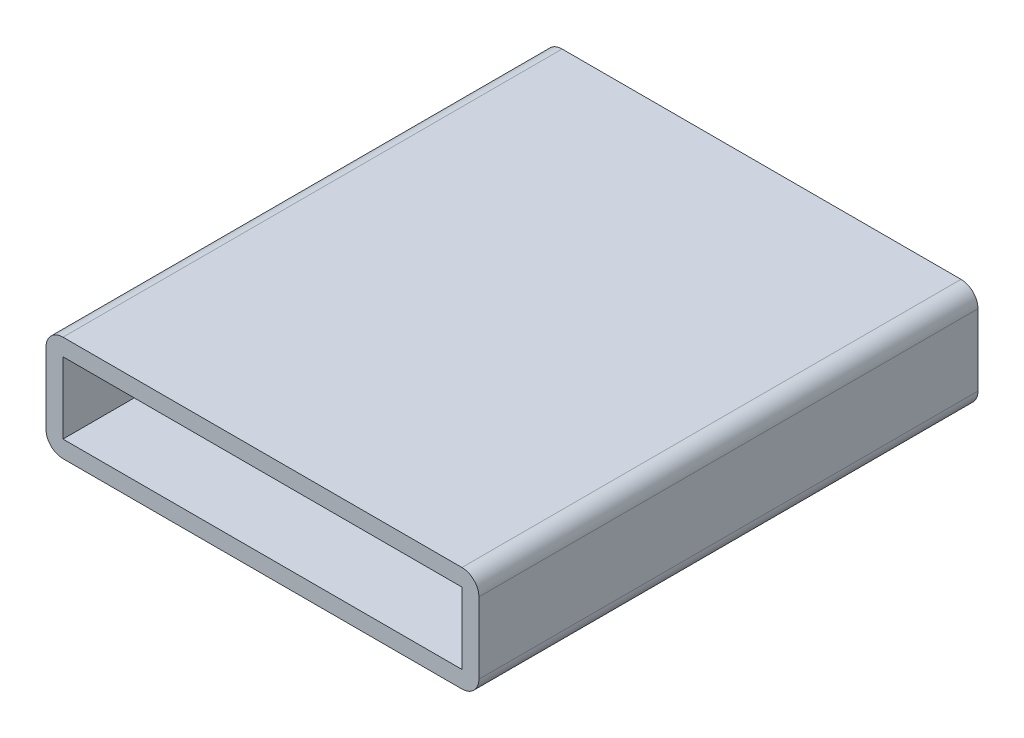
from build123d import *

# Parameters (mm, degrees)
SKETCH1_W           = 32.385
SKETCH1_H           = 7.874
SKETCH1_W_2         = 29.845
SKETCH1_H_2         = 5.334
BOSS_EXTRUDE1_DEPTH = 37.338
FILLET1_R           = 1.27
SKETCH2_W           = 29.845
SKETCH2_H           = 5.334
BOSS_EXTRUDE2_DEPTH = 1.27


with BuildPart() as part:
    # Sketch1 → Boss-Extrude1 (new body)
    with BuildSketch(Plane.XY):
        Rectangle(SKETCH1_W, SKETCH1_H)
        Rectangle(SKETCH1_W_2, SKETCH1_H_2, mode=Mode.SUBTRACT)
    extrude(amount=-BOSS_EXTRUDE1_DEPTH)

    # Fillet1
    fillet1_edges = [part.edges().sort_by_distance(p)[0] for p in [
        (16.1925, -3.937, -18.669),
        (-16.1925, -3.937, -18.669),
        (-16.1925, 3.937, -18.669),
        (16.1925, 3.937, -18.669),
    ]]
    fillet(fillet1_edges, radius=FILLET1_R)

    # Sketch2 → Boss-Extrude2 (add)
    with BuildSketch(Plane(origin=(0, 0, -37.338), x_dir=(-1, 0, 0), z_dir=(0, 0, -1))):
        Rectangle(SKETCH2_W, SKETCH2_H)
        with BuildLine():
            Line((-2.794, 2.54), (2.794, 2.54))
            ThreePointArc((2.794, 2.54), (3.51242049, 2.24242049), (3.81, 1.524))
            Line((3.81, 1.524), (3.81, -1.524))
            ThreePointArc((3.81, -1.524), (3.51242049, -2.24242049), (2.794, -2.54))
            Line((2.794, -2.54), (-2.794, -2.54))
            ThreePointArc((-2.794, -2.54), (-3.51242049, -2.24242049), (-3.81, -1.524))
            Line((-3.81, -1.524), (-3.81, 1.524))
            ThreePointArc((-3.81, 1.524), (-3.51242049, 2.24242049), (-2.794, 2.54))
        make_face(mode=Mode.SUBTRACT)
    extrude(amount=-BOSS_EXTRUDE2_DEPTH)


solid = part.part
